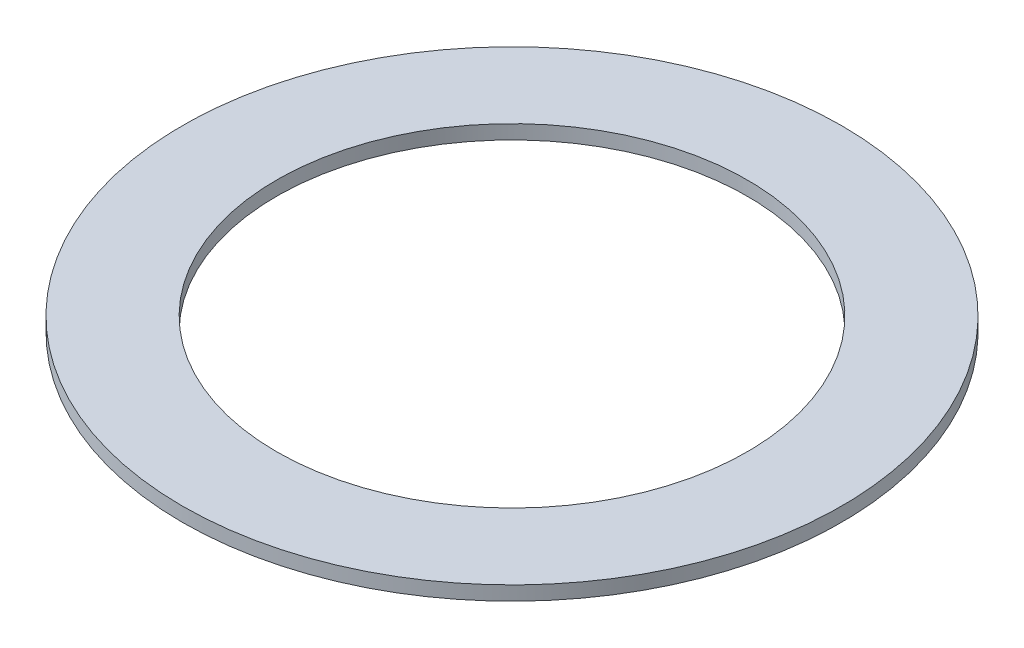
from build123d import *

# Parameters (mm, degrees)
CENTERING_RING_EXTRUDE_DEPTH           = 1.905
CENTERING_RING_EXTRUDE_DEPTH_BACK      = 1.905
F_98MM_6ID_CENTERING_RING_SKETCH_7_R   = 88.9
F_98MM_6ID_CENTERING_RING_SKETCH_7_R_2 = 63.5


with BuildPart() as part:
    # 98mm - 6ID centering ring sketch_7 → Centering Ring Extrude (new, two sides: drawn at the far end of the back side and taken through both)
    with BuildSketch(Plane(origin=(0, 0, 0), x_dir=(1, 0, 0), z_dir=(0, 1, 0)).offset(-CENTERING_RING_EXTRUDE_DEPTH_BACK)):
        Circle(F_98MM_6ID_CENTERING_RING_SKETCH_7_R)
        Circle(F_98MM_6ID_CENTERING_RING_SKETCH_7_R_2, mode=Mode.SUBTRACT)
    extrude(amount=CENTERING_RING_EXTRUDE_DEPTH + CENTERING_RING_EXTRUDE_DEPTH_BACK)


solid = part.part
